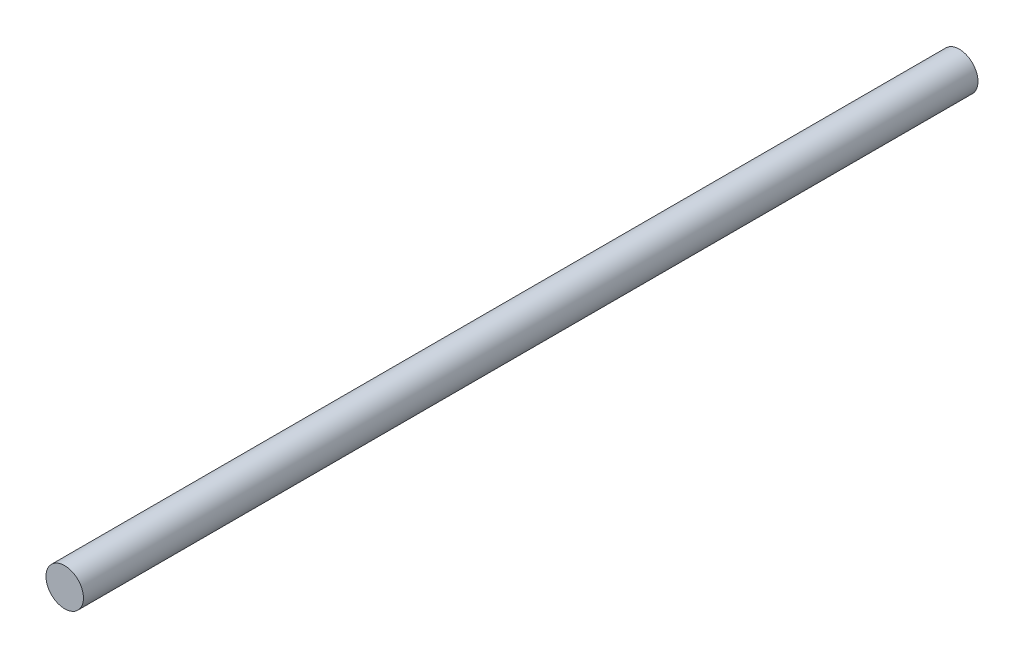
from build123d import *

# Parameters (mm, degrees)
SKETCH1_R           = 8
BOSS_EXTRUDE1_DEPTH = 191


with BuildPart() as part:
    # Sketch1 → Boss-Extrude1 (new body, symmetric)
    with BuildSketch(Plane.XY):
        Circle(SKETCH1_R)
    extrude(amount=BOSS_EXTRUDE1_DEPTH, both=True)


solid = part.part
